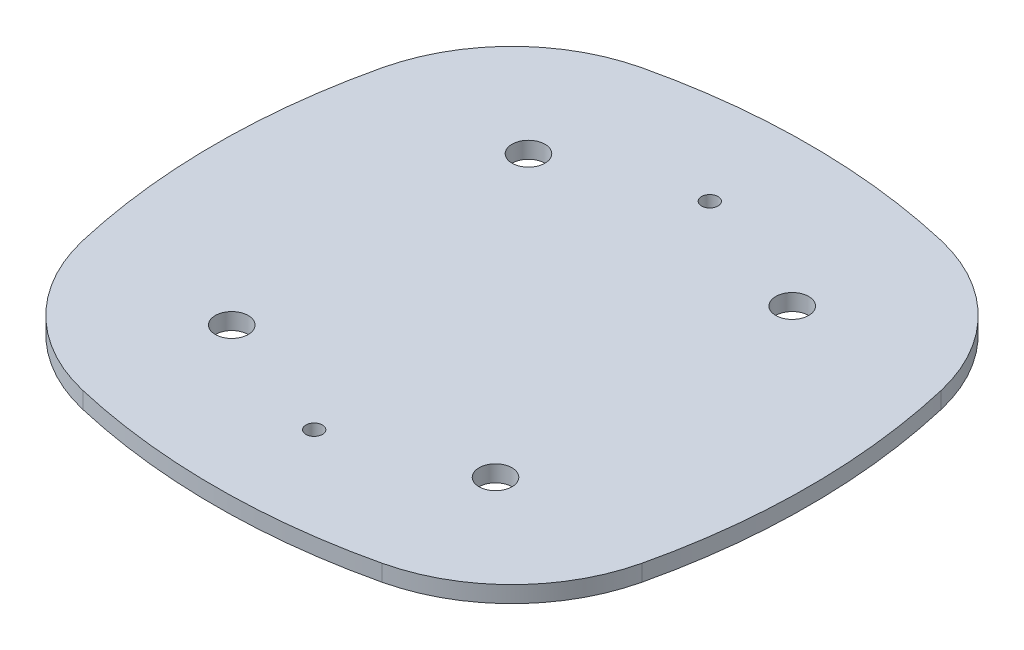
from build123d import *

# Parameters (mm, degrees)
SKETCH1_R      = 0.5
SKETCH1_R_2    = 0.25
EXTRUDE1_DEPTH = 0.5


with BuildPart() as part:
    # Sketch1 → Extrude1 (new body)
    with BuildSketch(Plane(origin=(0, 0, 0), x_dir=(1, 0, 0), z_dir=(0, 1, 0))):
        with BuildLine():
            ThreePointArc((8.478240258, -4.538519193), (9, 0), (8.478240258, 4.538519193))
            ThreePointArc((8.478240258, 4.538519193), (7.071067812, 7.071067812), (4.538519193, 8.478240258))
            ThreePointArc((4.538519193, 8.478240258), (0, 9), (-4.538519193, 8.478240258))
            ThreePointArc((-4.538519193, 8.478240258), (-7.071067812, 7.071067812), (-8.478240258, 4.538519193))
            ThreePointArc((-8.478240258, 4.538519193), (-9, 0), (-8.478240258, -4.538519193))
            ThreePointArc((-8.478240258, -4.538519193), (-7.071067812, -7.071067812), (-4.538519193, -8.478240258))
            ThreePointArc((-4.538519193, -8.478240258), (0, -9), (4.538519193, -8.478240258))
            ThreePointArc((4.538519193, -8.478240258), (7.071067812, -7.071067812), (8.478240258, -4.538519193))
        make_face()
        with Locations((4, 4.5)):
            Circle(SKETCH1_R, mode=Mode.SUBTRACT)
        with Locations((-4, 4.5)):
            Circle(SKETCH1_R, mode=Mode.SUBTRACT)
        with Locations((4, -4.5)):
            Circle(SKETCH1_R, mode=Mode.SUBTRACT)
        with Locations((-4, -4.5)):
            Circle(SKETCH1_R, mode=Mode.SUBTRACT)
        with Locations((0, 6)):
            Circle(SKETCH1_R_2, mode=Mode.SUBTRACT)
        with Locations((0, -6)):
            Circle(SKETCH1_R_2, mode=Mode.SUBTRACT)
    extrude(amount=EXTRUDE1_DEPTH)


solid = part.part
